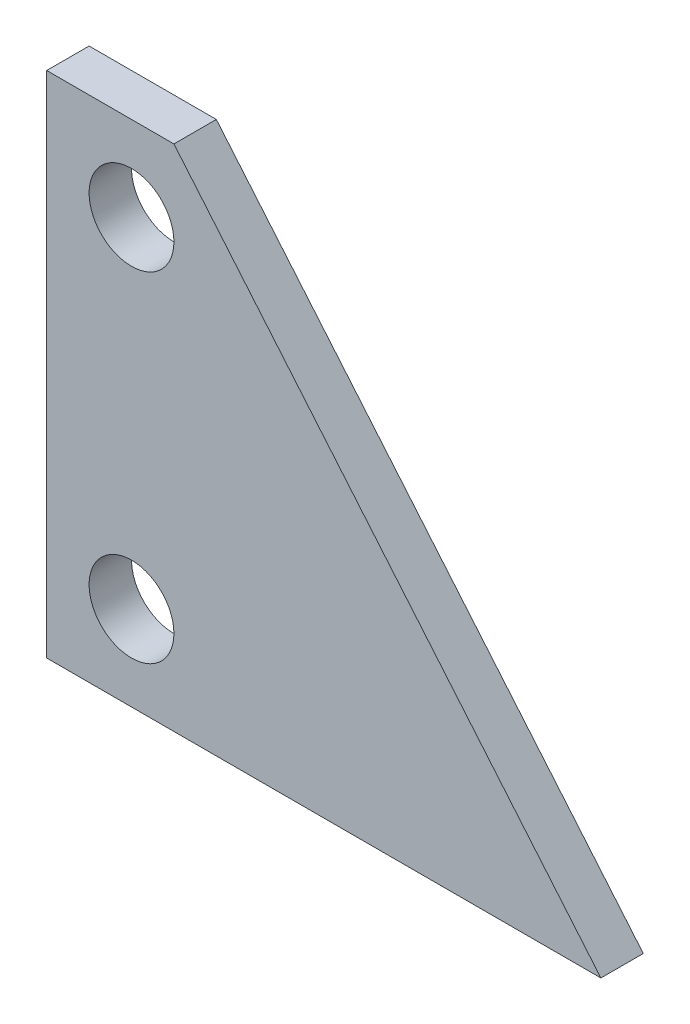
from build123d import *

# Parameters (mm, degrees)
SKETCH1_R           = 6.35
BOSS_EXTRUDE1_DEPTH = 3.175


with BuildPart() as part:
    # Sketch1 → Boss-Extrude1 (new body, symmetric)
    with BuildSketch(Plane.XY):
        Polygon((0, 0), (82.989391896, 0), (19.05, 76.2), (0, 76.2), align=None)
        with Locations((12.7, 63.5)):
            Circle(SKETCH1_R, mode=Mode.SUBTRACT)
        with Locations((12.7, 12.7)):
            Circle(SKETCH1_R, mode=Mode.SUBTRACT)
    extrude(amount=BOSS_EXTRUDE1_DEPTH, both=True)


solid = part.part
